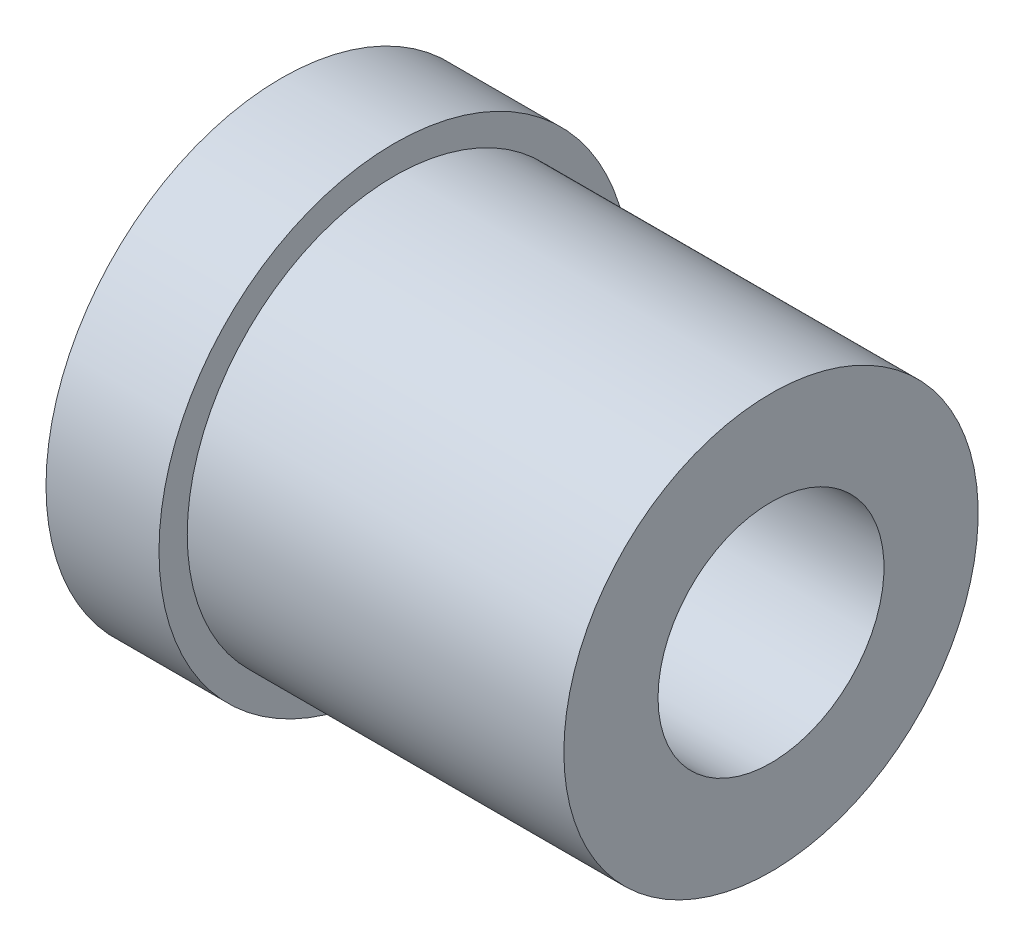
from build123d import *


with BuildPart() as part:
    # Эскиз1 → Повернуть1 (revolve)
    with BuildSketch(Plane.XY):
        Polygon((0, 12.5), (0, 6), (26, 6), (26, 11), (6, 11), (6, 12.5), align=None)
    revolve(axis=Axis((0, 0, 0), (1, 0, 0)))


solid = part.part
